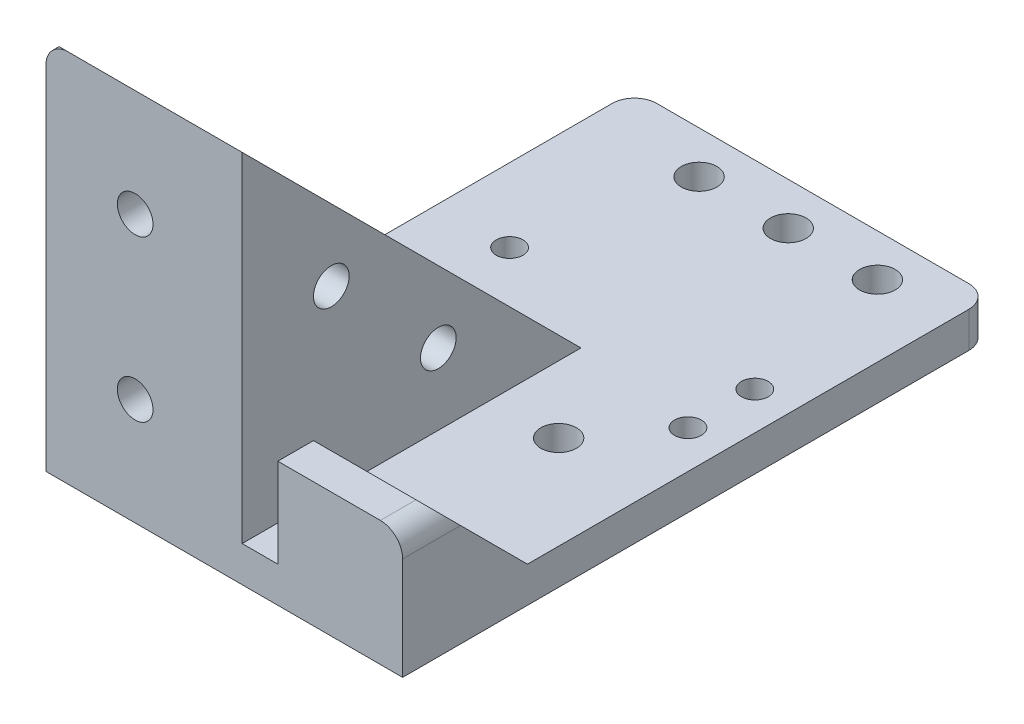
from build123d import *

# Parameters (mm, degrees)
BOSS_EXTRUDE1_DEPTH  = 4
SKETCH2_R            = 2
SKETCH2_R_2          = 1.5
CUT_EXTRUDE1_DEPTH   = 5
BOSS_EXTRUDE5_DEPTH  = 4
SKETCH6_W            = 18
SKETCH6_H            = 34
BOSS_EXTRUDE6_DEPTH  = 4
SKETCH7_W            = 14
SKETCH7_H            = 10
BOSS_EXTRUDE7_DEPTH  = 4
SKETCH8_R            = 2
CUT_EXTRUDE2_DEPTH   = 23
SKETCH9_R            = 2
CUT_EXTRUDE3_DEPTH   = 4
BOSS_EXTRUDE8_DEPTH  = 22
BOSS_EXTRUDE9_DEPTH  = 4
BOSS_EXTRUDE10_DEPTH = 4
CUT_EXTRUDE5_DEPTH   = 4
FILLET7_R            = 2.5
FILLET8_R            = 2.5


with BuildPart() as part:
    # Sketch1 → Boss-Extrude1 (new body)
    with BuildSketch(Plane(origin=(0, 0, 0), x_dir=(1, 0, 0), z_dir=(0, 1, 0))):
        Polygon((-20, 66), (20, 66), (20, 6), (20, 0), (-20, 0), (-20, 6), align=None)
    extrude(amount=BOSS_EXTRUDE1_DEPTH)

    # Sketch2 → Cut-Extrude1 (cut, through all)
    with BuildSketch(Plane(origin=(0, 4, 0), x_dir=(1, 0, 0), z_dir=(0, 1, 0))):
        with Locations((-8.00387182, 61.25)):
            Circle(SKETCH2_R)
        with Locations((1.99612818, 61.25)):
            Circle(SKETCH2_R)
        with Locations((11.99612818, 61.25)):
            Circle(SKETCH2_R)
        with Locations((-5.50387182, 8)):
            Circle(SKETCH2_R)
        with Locations((-5.50387182, 28)):
            Circle(SKETCH2_R)
        with Locations((9.49612818, 28)):
            Circle(SKETCH2_R)
        with Locations((9.49612818, 8)):
            Circle(SKETCH2_R)
        with Locations((15.74612818, 36.25)):
            Circle(SKETCH2_R_2)
        with Locations((15.74612818, 43.75)):
            Circle(SKETCH2_R_2)
        with Locations((-11.75387182, 43.75)):
            Circle(SKETCH2_R_2)
        with Locations((-11.75387182, 36.25)):
            Circle(SKETCH2_R_2)
    extrude(amount=-CUT_EXTRUDE1_DEPTH, mode=Mode.SUBTRACT)

    # Sketch5 → Boss-Extrude5 (add)
    with BuildSketch(Plane(origin=(2, 0, 0), x_dir=(0, 0, -1), z_dir=(1, 0, 0))):
        Polygon((0, 4), (0, 38), (4, 38), (38, 4), align=None)
    extrude(amount=-BOSS_EXTRUDE5_DEPTH)

    # Sketch6 → Boss-Extrude6 (add)
    with BuildSketch(Plane.XY):
        with Locations((-11, 21)):
            Rectangle(SKETCH6_W, SKETCH6_H)
    extrude(amount=-BOSS_EXTRUDE6_DEPTH)

    # Sketch7 → Boss-Extrude7 (add)
    with BuildSketch(Plane.XY):
        with Locations((13, 9)):
            Rectangle(SKETCH7_W, SKETCH7_H)
    extrude(amount=-BOSS_EXTRUDE7_DEPTH)

    # Sketch8 → Cut-Extrude2 (cut, through all)
    with BuildSketch(Plane.ZY.offset(2)):
        with Locations((-10, 24)):
            Circle(SKETCH8_R)
        with Locations((-22, 12)):
            Circle(SKETCH8_R)
    extrude(amount=-CUT_EXTRUDE2_DEPTH, mode=Mode.SUBTRACT)

    # Sketch9 → Cut-Extrude3 (cut)
    with BuildSketch(Plane(origin=(0, 0, -4), x_dir=(-1, 0, 0), z_dir=(0, 0, -1))):
        with Locations((10, 12)):
            Circle(SKETCH9_R)
        with Locations((10, 30)):
            Circle(SKETCH9_R)
    extrude(amount=-CUT_EXTRUDE3_DEPTH, mode=Mode.SUBTRACT)

    # Sketch10 → Boss-Extrude8 (add)
    with BuildSketch(Plane(origin=(2, 0, 0), x_dir=(0, 0, -1), z_dir=(1, 0, 0))):
        Polygon((4, 38), (0, 42), (0, 38), align=None)
    extrude(amount=-BOSS_EXTRUDE8_DEPTH)

    # Sketch13 → Boss-Extrude9 (add)
    with BuildSketch(Plane(origin=(20, 0, 0), x_dir=(0, 0, -1), z_dir=(1, 0, 0))):
        Polygon((4, 14), (14, 4), (4, 4), align=None)
    extrude(amount=-BOSS_EXTRUDE9_DEPTH)

    # Sketch14 → Boss-Extrude10 (add)
    with BuildSketch(Plane.ZY.offset(20)):
        Polygon((-4, 38), (-38, 4), (-4, 4), align=None)
    extrude(amount=-BOSS_EXTRUDE10_DEPTH)

    # Sketch16 → Cut-Extrude5 (cut)
    with BuildSketch(Plane.XY):
        with BuildLine():
            Line((-20, 42), (-20, 39.566764618))
            ThreePointArc((-20, 39.566764618), (-19.278186488, 41.259842846), (-17.593046725, 42))
            Line((-17.593046725, 42), (-20, 42))
        make_face()
    extrude(amount=-CUT_EXTRUDE5_DEPTH, mode=Mode.SUBTRACT)

    # Fillet7
    fillet7_edges = [part.edges().sort_by_distance(p)[0] for p in [
        (-20, 2, -66),
        (20, 2, -66),
    ]]
    fillet(fillet7_edges, radius=FILLET7_R)

    # Fillet8
    fillet8_edges = [part.edges().sort_by_distance(p)[0] for p in [
        (20, 14, -2),
    ]]
    fillet(fillet8_edges, radius=FILLET8_R)


solid = part.part
